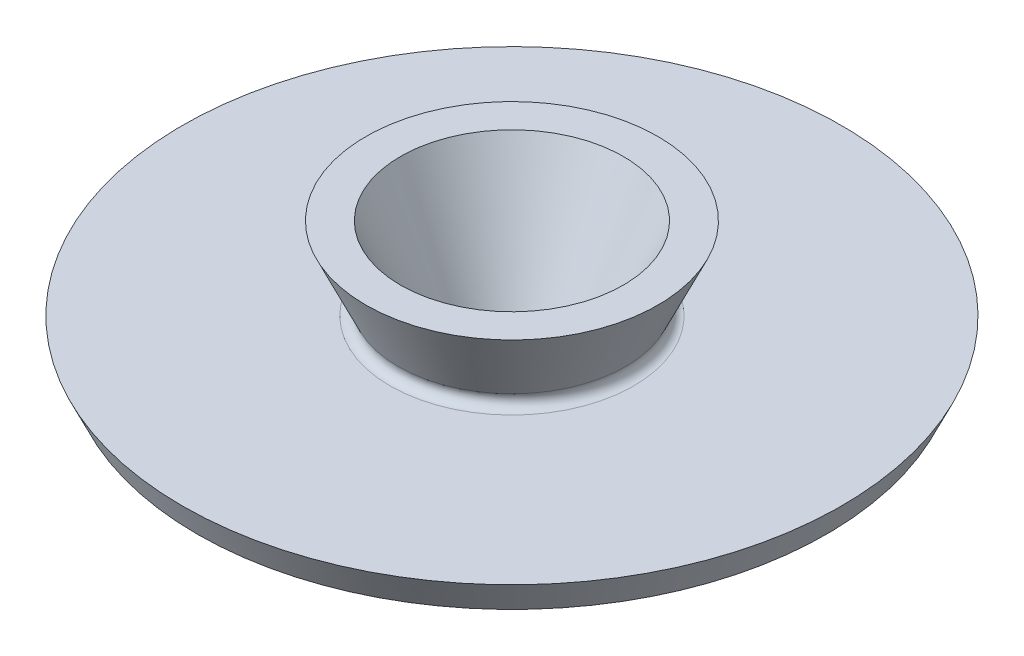
from build123d import *


with BuildPart() as part:
    # Sketch1 → Revolve2 (revolve)
    with BuildSketch(Plane.XY):
        with BuildLine():
            Line((-93.673844241, 4.489394889), (-89.446968139, -4.575170165))
            Line((-89.446968139, -4.575170165), (-20.47353757, -4.575170165))
            Line((-20.47353757, -4.575170165), (-17.8286148, -10.247225348))
            Line((-17.8286148, -10.247225348), (-13.919327146, -10.247225348))
            Line((-13.919327146, -10.247225348), (-31.685648922, 27.852774652))
            Line((-31.685648922, 27.852774652), (-41.510319076, 27.852774652))
            Line((-41.510319076, 27.852774652), (-32.300775759, 8.102845274))
            ThreePointArc((-32.300775759, 8.102845274), (-32.460583266, 5.664653884), (-34.602797538, 4.489394889))
            Line((-34.602797538, 4.489394889), (-93.673844241, 4.489394889))
        make_face()
    revolve(axis=Axis((0, 77.135966731, 0), (0, -1, 0)))


solid = part.part
